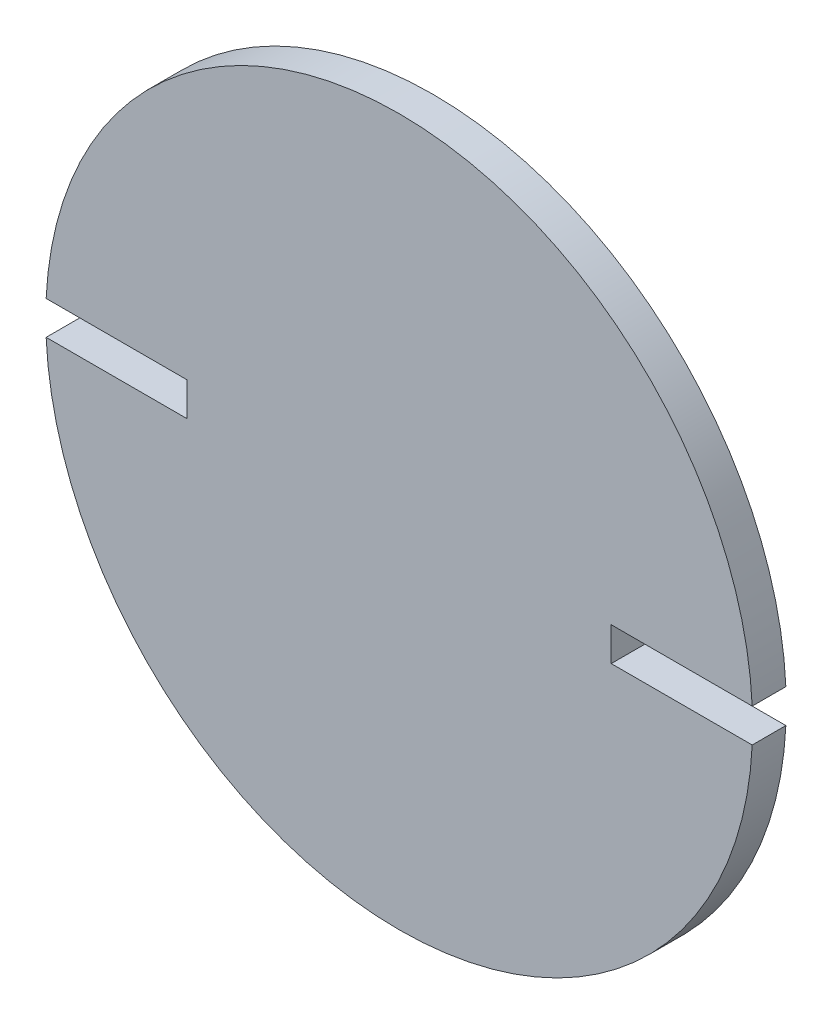
from build123d import *

# Parameters (mm, degrees)
SKETCH1_R           = 66.675
BOSS_EXTRUDE1_DEPTH = 6.35
CUT_EXTRUDE1_DEPTH  = 7.35


with BuildPart() as part:
    # Sketch1 → Boss-Extrude1 (new body)
    with BuildSketch(Plane.XY):
        Circle(SKETCH1_R)
    extrude(amount=BOSS_EXTRUDE1_DEPTH)

    # Sketch2 → Cut-Extrude1 (cut, through all)
    with BuildSketch(Plane.XY.offset(6.35)):
        Polygon((-40.005, 0), (-40.005, 3.175), (-67.945, 3.175), (-67.945, -3.175), (-40.005, -3.175), align=None)
        Polygon((40.005, -3.175), (40.005, 0), (40.005, 3.175), (67.945, 3.175), (67.945, -3.175), align=None)
    extrude(amount=-CUT_EXTRUDE1_DEPTH, mode=Mode.SUBTRACT)


solid = part.part
